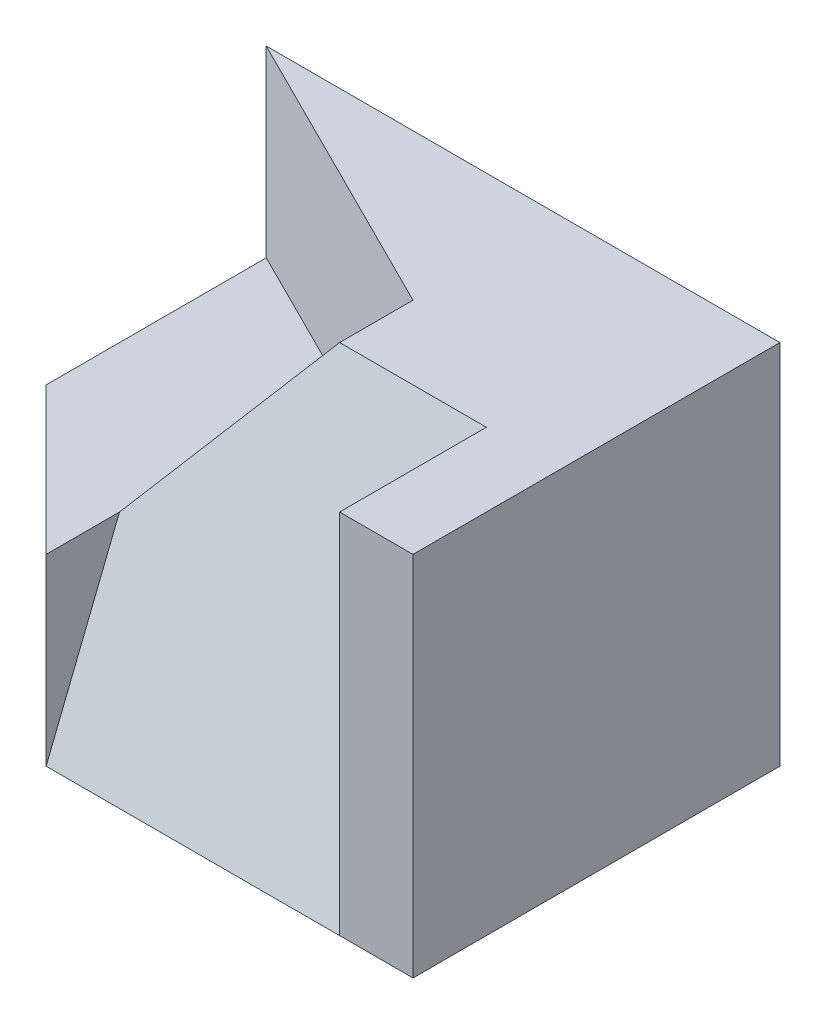
from build123d import *

# Parameters (mm, degrees)
SKETCH1_W            = 70
SKETCH1_H            = 50
BOSS_EXTRUDE1_DEPTH  = 50
CUT_EXTRUDE1_DEPTH   = 50
CUT_EXTRUDE2_DEPTH   = 20
CUT_EXTRUDE3_DEPTH   = 20
CUT_EXTRUDE4_DEPTH   = 5
BOSS_EXTRUDE2_DEPTH  = 25
CUT_EXTRUDE5_DEPTH   = 25
BOSS_EXTRUDE3_DEPTH  = 30
BOSS_EXTRUDE4_DEPTH  = 50
CUT_EXTRUDE7_DEPTH   = 15
CUT_EXTRUDE8_DEPTH   = 15
BOSS_EXTRUDE5_DEPTH  = 15
CUT_EXTRUDE12_DEPTH  = 15
CUT_EXTRUDE13_DEPTH  = 15
BOSS_EXTRUDE6_DEPTH  = 15
SKETCH22_W           = 70
SKETCH22_H           = 50
CUT_EXTRUDE15_DEPTH  = 15
BOSS_EXTRUDE11_DEPTH = 15
CUT_EXTRUDE18_DEPTH  = 15
CUT_EXTRUDE19_DEPTH  = 15
BOSS_EXTRUDE14_DEPTH = 15
BOSS_EXTRUDE17_DEPTH = 25
BOSS_EXTRUDE18_DEPTH = 25


with BuildPart() as part:
    # Sketch1 → Boss-Extrude1 (new body)
    with BuildSketch(Plane.XY):
        with Locations((35, 25)):
            Rectangle(SKETCH1_W, SKETCH1_H)
    extrude(amount=BOSS_EXTRUDE1_DEPTH)

    # Sketch2 → Cut-Extrude1 (cut)
    with BuildSketch(Plane.XZ):
        Polygon((0, 30), (20, 50), (0, 50), align=None)
    extrude(amount=-CUT_EXTRUDE1_DEPTH, mode=Mode.SUBTRACT)

    # Sketch3 → Cut-Extrude2 (cut)
    with BuildSketch(Plane.XY.offset(50)):
        Polygon((60, 0), (60, 50), (40, 50), (20, 30), (20, 0), align=None)
    extrude(amount=-CUT_EXTRUDE2_DEPTH, mode=Mode.SUBTRACT)

    # Sketch4 → Cut-Extrude3 (cut)
    with BuildSketch(Plane(origin=(0, 50, 0), x_dir=(1, 0, 0), z_dir=(0, 1, 0))):
        Polygon((40, -30), (20, -50), (0, -30), (0, 0), (40, -20), align=None)
    extrude(amount=-CUT_EXTRUDE3_DEPTH, mode=Mode.SUBTRACT)

    # Sketch5 → Cut-Extrude4 (cut)
    with BuildSketch(Plane(origin=(0, 30, 0), x_dir=(1, 0, 0), z_dir=(0, 1, 0))):
        Polygon((0, 0), (0, -30), (20, -50), (20, -30), (40, -30), (40, -20), align=None)
    extrude(amount=-CUT_EXTRUDE4_DEPTH, mode=Mode.SUBTRACT)

    # Sketch6 → Boss-Extrude2 (add)
    with BuildSketch(Plane(origin=(0, 25, 0), x_dir=(1, 0, 0), z_dir=(0, 1, 0))):
        Polygon((20, -10), (20, -30), (40, -30), (40, -20), align=None)
    extrude(amount=BOSS_EXTRUDE2_DEPTH)

    # Sketch7 → Cut-Extrude5 (cut)
    with BuildSketch(Plane(origin=(0, 50, 0), x_dir=(1, 0, 0), z_dir=(0, 1, 0))):
        Polygon((20, -50), (40, -50), (40, -30), align=None)
    extrude(amount=-CUT_EXTRUDE5_DEPTH, mode=Mode.SUBTRACT)

    # Sketch8 → Boss-Extrude3 (add)
    with BuildSketch(Plane.XZ):
        Polygon((20, 50), (20, 40), (40, 30), (60, 30), (60, 50), align=None)
    extrude(amount=-BOSS_EXTRUDE3_DEPTH)

    # Sketch9 → Boss-Extrude4 (add)
    with BuildSketch(Plane(origin=(0, 50, 0), x_dir=(1, 0, 0), z_dir=(0, 1, 0))):
        Polygon((20, -40), (40, -30), (20, -30), align=None)
    extrude(amount=-BOSS_EXTRUDE4_DEPTH)

    # Sketch10 → Cut-Extrude7 (cut)
    with BuildSketch(Plane(origin=(0, 50, 0), x_dir=(1, 0, 0), z_dir=(0, 1, 0))):
        Polygon((20, -40), (40, -30), (40, -20), (20, -10), align=None)
    extrude(amount=-CUT_EXTRUDE7_DEPTH, mode=Mode.SUBTRACT)

    # Sketch11 → Cut-Extrude8 (cut)
    with BuildSketch(Plane(origin=(0, 17.24137931, 43.103448276), x_dir=(1, 0, 0), z_dir=(0, 0.371390676, 0.928476691))):
        Polygon((60, 35.282114254), (60, -18.569533818), (20, -18.569533818), (20, 4.642383454), (40, 35.282114254), align=None)
    extrude(amount=CUT_EXTRUDE8_DEPTH, mode=Mode.SUBTRACT)

    # Sketch12 → Boss-Extrude5 (add)
    with BuildSketch(Plane(origin=(0, 17.24137931, 43.103448276), x_dir=(1, 0, 0), z_dir=(0, 0.371390676, 0.928476691))):
        Polygon((40, 35.282114254), (60, 35.282114254), (60, -18.569533818), (20, -18.569533818), (20, 4.642383454), align=None)
    extrude(amount=-BOSS_EXTRUDE5_DEPTH)

    # Sketch13 → Cut-Extrude12 (cut)
    with BuildSketch(Plane(origin=(11.899549259, -7.211848036, 2.884739214), x_dir=(0.173608446, -0.10521724, -0.979177941), z_dir=(0.837390852, -0.507509607, 0.203003843))):
        Polygon((-48.11715912, 31.745980111), (-48.11715912, 37.592580529), (-35.861981078, 39.10036734), (-39.313151906, 28.797022071), align=None)
    extrude(amount=-CUT_EXTRUDE12_DEPTH, mode=Mode.SUBTRACT)

    # Sketch15 → Cut-Extrude13 (cut)
    with BuildSketch(Plane(origin=(0, 17.24137931, 43.103448276), x_dir=(1, 0, 0), z_dir=(0, 0.371390676, 0.928476691))):
        Polygon((40, 35.282114254), (20, 35.282114254), (20, -18.569533818), align=None)
    extrude(amount=CUT_EXTRUDE13_DEPTH, mode=Mode.SUBTRACT)

    # Sketch16 → Boss-Extrude6 (add)
    with BuildSketch(Plane(origin=(0, 17.24137931, 43.103448276), x_dir=(1, 0, 0), z_dir=(0, 0.371390676, 0.928476691))):
        Polygon((25.939393939, 13.741455025), (28, 19.126619832), (24, 13.741455025), align=None)
        Polygon((28, 19.126619832), (25.939393939, 13.741455025), (29.454545455, 19.126619832), align=None)
    extrude(amount=-BOSS_EXTRUDE6_DEPTH)

    # Sketch22 → Cut-Extrude15 (cut)
    with BuildSketch(Plane(origin=(0, 0, 0), x_dir=(-1, 0, 0), z_dir=(0, -1, 0))):
        with Locations((-35, -25)):
            Rectangle(SKETCH22_W, SKETCH22_H)
    extrude(amount=CUT_EXTRUDE15_DEPTH, mode=Mode.SUBTRACT)

    # Sketch28 → Boss-Extrude11 (add)
    with BuildSketch(Plane(origin=(-9.6, 12.8, 0), x_dir=(0.8, 0.6, 0), z_dir=(-0.6, 0.8, 0))):
        Polygon((37, -36), (62, -30), (62, -20), (37, -10), align=None)
    extrude(amount=-BOSS_EXTRUDE11_DEPTH)

    # Sketch29 → Cut-Extrude18 (cut)
    with BuildSketch(Plane(origin=(0, 0, 0), x_dir=(0, 0, -1), z_dir=(0.780868809, -0.624695048, 0))):
        Polygon((-40, 32.015621187), (-30, 64.031242374), (-20, 64.031242374), (-10, 32.015621187), align=None)
    extrude(amount=-CUT_EXTRUDE18_DEPTH, mode=Mode.SUBTRACT)

    # Sketch30 → Cut-Extrude19 (cut)
    with BuildSketch(Plane(origin=(0, 0, 0), x_dir=(0.894427191, 0, 0.447213595), z_dir=(-0.447213595, 0, 0.894427191))):
        Polygon((0, 50), (44.72135955, 50), (22.360679775, 25), (0, 25), align=None)
    extrude(amount=CUT_EXTRUDE19_DEPTH, mode=Mode.SUBTRACT)

    # Sketch32 → Boss-Extrude14 (add)
    with BuildSketch(Plane(origin=(0, 17.24137931, 43.103448276), x_dir=(1, 0, 0), z_dir=(0, 0.371390676, 0.928476691))):
        Polygon((28, 19.126619832), (40, 35.282114254), (29.454545455, 19.126619832), align=None)
    extrude(amount=-BOSS_EXTRUDE14_DEPTH)

    # Sketch34 → Boss-Extrude17 (add)
    with BuildSketch(Plane(origin=(0, 25, 0), x_dir=(1, 0, 0), z_dir=(0, 1, 0))):
        Polygon((14.310344828, -40), (20, -40), (20, -50), align=None)
    extrude(amount=-BOSS_EXTRUDE17_DEPTH)

    # Sketch35 → Boss-Extrude18 (add)
    with BuildSketch(Plane(origin=(0, 0, 0), x_dir=(0, 0, 1), z_dir=(-0.780868809, 0.624695048, 0))):
        Polygon((30, 64.031242374), (40, 32.015621187), (10, 32.015621187), (20, 64.031242374), align=None)
    extrude(amount=-BOSS_EXTRUDE18_DEPTH)


solid = part.part
